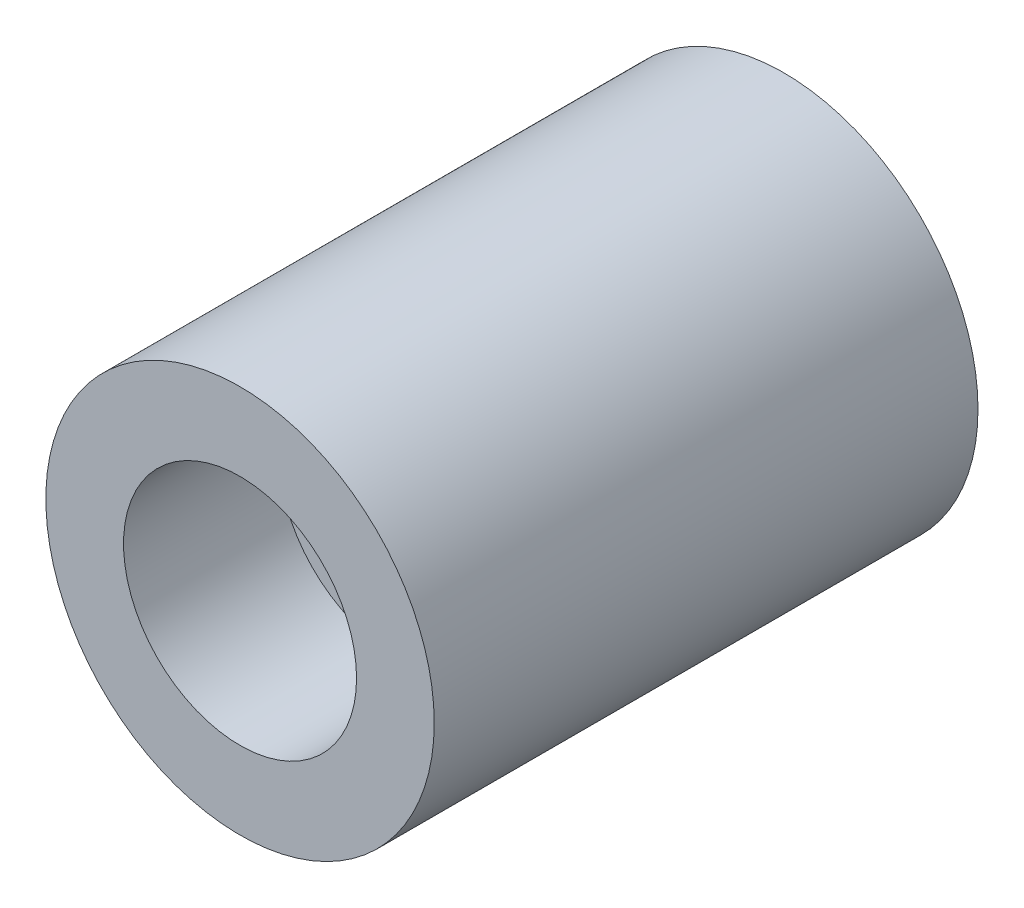
from build123d import *

# Parameters (mm, degrees)
SKETCH1_R           = 50
BOSS_EXTRUDE1_DEPTH = 140
SKETCH2_R           = 30
CUT_EXTRUDE1_DEPTH  = 40
SKETCH3_R           = 10
CUT_EXTRUDE2_DEPTH  = 120


with BuildPart() as part:
    # Sketch1 → Boss-Extrude1 (new body)
    with BuildSketch(Plane.XY):
        Circle(SKETCH1_R)
    extrude(amount=BOSS_EXTRUDE1_DEPTH)

    # Sketch2 → Cut-Extrude1 (cut)
    with BuildSketch(Plane.XY.offset(140)):
        Circle(SKETCH2_R)
    extrude(amount=-CUT_EXTRUDE1_DEPTH, mode=Mode.SUBTRACT)

    # Sketch3 → Cut-Extrude2 (cut)
    with BuildSketch(Plane.XY.offset(140)):
        Circle(SKETCH3_R)
    extrude(amount=-CUT_EXTRUDE2_DEPTH, mode=Mode.SUBTRACT)


solid = part.part
